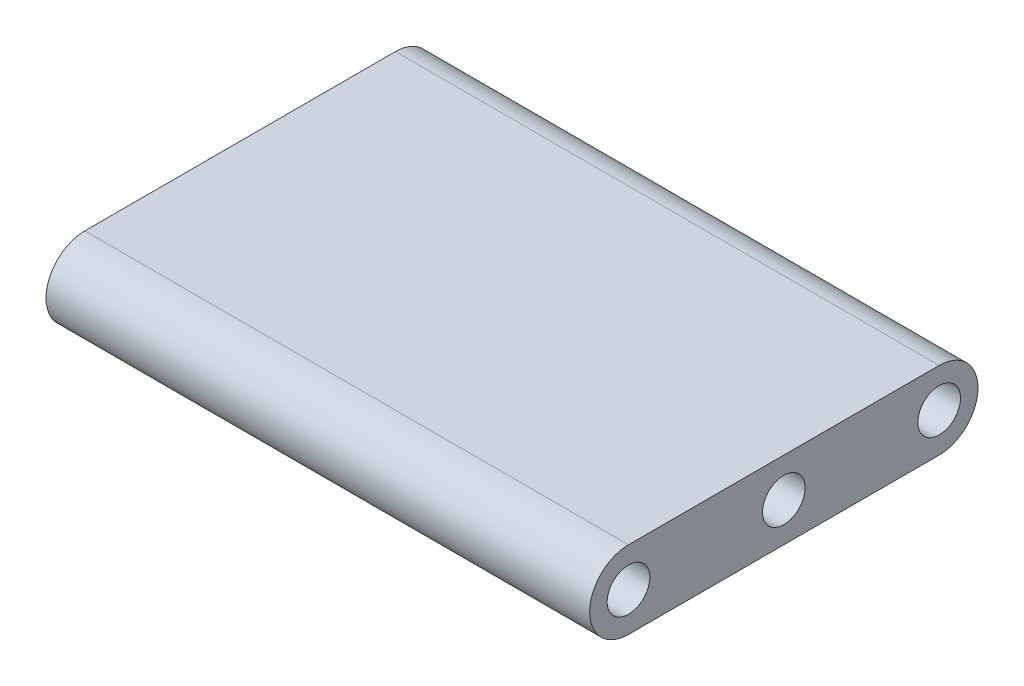
from build123d import *

# Parameters (mm, degrees)
SKETCH1_R           = 3.4925
BOSS_EXTRUDE1_DEPTH = 44.45


with BuildPart() as part:
    # Sketch1 → Boss-Extrude1 (new body, symmetric)
    with BuildSketch(Plane(origin=(0, 0, 0), x_dir=(0, 0, -1), z_dir=(1, 0, 0))):
        with BuildLine():
            Line((-25.4, -6.35), (25.4, -6.35))
            ThreePointArc((25.4, -6.35), (31.75, 0), (25.4, 6.35))
            Line((25.4, 6.35), (-25.4, 6.35))
            ThreePointArc((-25.4, 6.35), (-31.75, 0), (-25.4, -6.35))
        make_face()
        with Locations((-25.4, 0)):
            Circle(SKETCH1_R, mode=Mode.SUBTRACT)
        with Locations((25.4, 0)):
            Circle(SKETCH1_R, mode=Mode.SUBTRACT)
        Circle(SKETCH1_R, mode=Mode.SUBTRACT)
    extrude(amount=BOSS_EXTRUDE1_DEPTH, both=True)


solid = part.part
